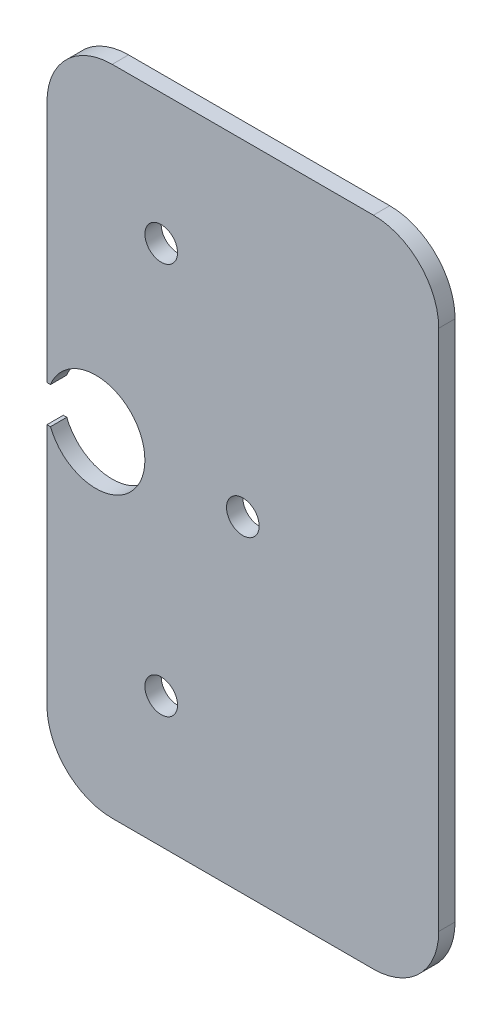
from build123d import *

# Parameters (mm, degrees)
SKETCH1_R           = 3.175
BOSS_EXTRUDE2_DEPTH = 3.175


with BuildPart() as part:
    # Sketch1 → Boss-Extrude2 (new body)
    with BuildSketch(Plane.XY):
        with BuildLine():
            add(Edge.make_bspline(
                [(-459.058883104, 1020.90986665), (-454.410065073, 1009.258459074), (-444.447409236, 1016.856993556), (-434.4847534, 1024.455528037), (-444.447409236, 1032.054062519), (-454.410065073, 1039.652597001), (-459.058883104, 1028.001189425)],
                knots=[1.951262384, 1.951262384, 1.951262384, 3.792013448, 3.792013448, 5.632764512, 5.632764512, 7.473515577, 7.473515577, 7.473515577], degree=2, weights=[1, 0.60552134, 1, 0.60552134, 1, 0.60552134, 1]))
            Line((-459.058883104, 1028.001189425), (-459.74, 1028.001189425))
            Line((-459.74, 1028.001189425), (-459.74, 1075.255528037))
            ThreePointArc((-459.74, 1075.255528037), (-456.020256121, 1084.235784159), (-447.04, 1087.955528037))
            Line((-447.04, 1087.955528037), (-396.24, 1087.955528037))
            ThreePointArc((-396.24, 1087.955528037), (-387.259743879, 1084.235784159), (-383.54, 1075.255528037))
            Line((-383.54, 1075.255528037), (-383.54, 973.655528037))
            ThreePointArc((-383.54, 973.655528037), (-387.259743879, 964.675271916), (-396.24, 960.955528037))
            Line((-396.24, 960.955528037), (-447.04, 960.955528037))
            ThreePointArc((-447.04, 960.955528037), (-456.020256121, 964.675271916), (-459.74, 973.655528037))
            Line((-459.74, 973.655528037), (-459.74, 1020.90986665))
            Line((-459.74, 1020.90986665), (-459.058883104, 1020.90986665))
        make_face()
        with Locations((-421.64, 1024.455528037)):
            Circle(SKETCH1_R, mode=Mode.SUBTRACT)
        with Locations((-437.515, 986.355528037)):
            Circle(SKETCH1_R, mode=Mode.SUBTRACT)
        with Locations((-437.515, 1062.555528037)):
            Circle(SKETCH1_R, mode=Mode.SUBTRACT)
    extrude(amount=BOSS_EXTRUDE2_DEPTH)


solid = part.part
